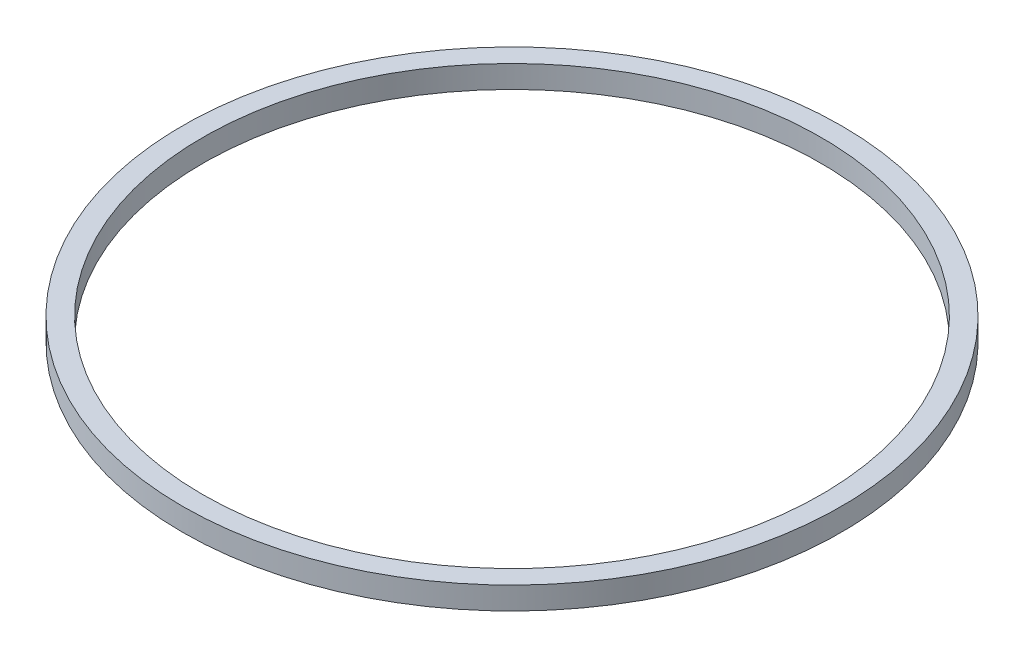
from build123d import *

# Parameters (mm, degrees)
SKETCH1_R           = 29.3
SKETCH1_R_2         = 27.5
BOSS_EXTRUDE1_DEPTH = 2


with BuildPart() as part:
    # Sketch1 → Boss-Extrude1 (new body)
    with BuildSketch(Plane(origin=(0, 0, 0), x_dir=(1, 0, 0), z_dir=(0, 1, 0))):
        Circle(SKETCH1_R)
        Circle(SKETCH1_R_2, mode=Mode.SUBTRACT)
    extrude(amount=BOSS_EXTRUDE1_DEPTH)


solid = part.part
